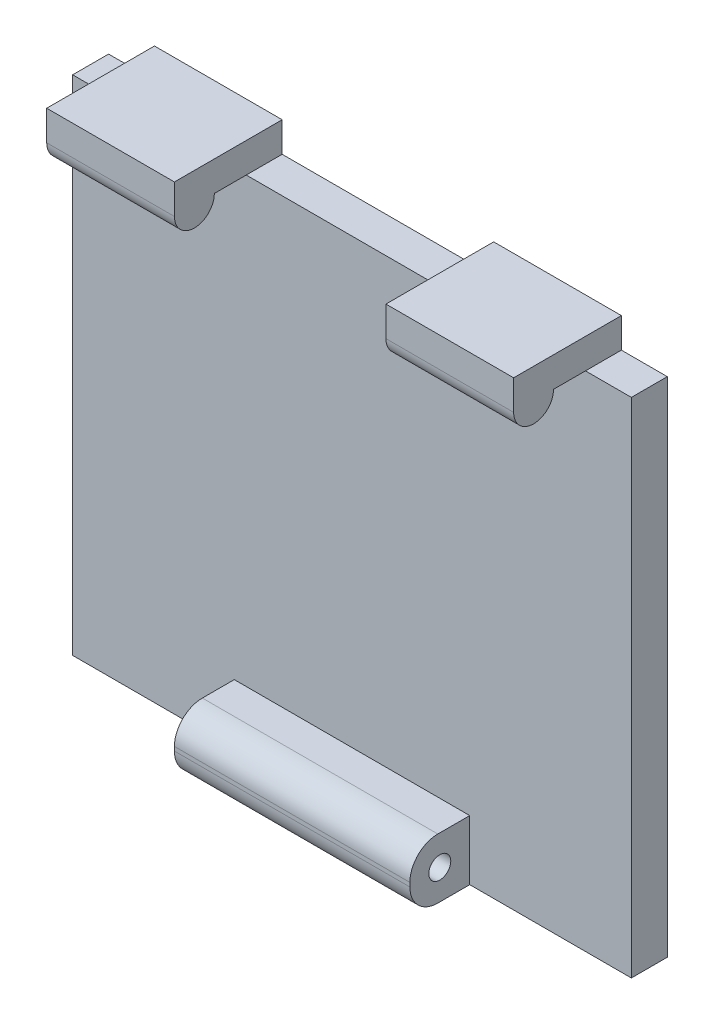
from build123d import *

# Parameters (mm, degrees)
SKETCH_1_W          = 28
SKETCH_1_H          = 25.2
EXTRUDE_1_DEPTH     = 1.8
SKETCH_2_W          = 11.8
SKETCH_2_H          = 3
EXTRUDE_2_DEPTH     = 3
FILLET_1_R          = 1.4
SKETCH_3_R          = 0.55
CUT_EXTRUDE_1_DEPTH = 20.9
SKETCH_4_W          = 6.4
SKETCH_4_H          = 1.8
EXTRUDE_3_DEPTH     = 1.5
SKETCH_5_W          = 6.4
SKETCH_5_H          = 1.5
EXTRUDE_4_DEPTH     = 3.6
SKETCH_7_R          = 1
EXTRUDE_5_DEPTH     = 6.4
SKETCH_8_R          = 1
EXTRUDE_6_DEPTH     = 6.4


with BuildPart() as part:
    # 草图1 → 凸台-拉伸1 (new body)
    with BuildSketch(Plane.XY):
        with Locations((14, -12.6)):
            Rectangle(SKETCH_1_W, SKETCH_1_H)
    extrude(amount=EXTRUDE_1_DEPTH)

    # 草图2 → 凸台-拉伸2 (add)
    with BuildSketch(Plane.XY.offset(1.8)):
        with Locations((14, -23.7)):
            Rectangle(SKETCH_2_W, SKETCH_2_H)
    extrude(amount=EXTRUDE_2_DEPTH)

    # 圆角1
    fillet_1_edges = [part.edges().sort_by_distance(p)[0] for p in [
        (14, -25.2, 4.8),
        (14, -22.2, 4.8),
    ]]
    fillet(fillet_1_edges, radius=FILLET_1_R)

    # 草图3 → 切除-拉伸1 (cut, through all)
    with BuildSketch(Plane(origin=(19.9, 0, 0), x_dir=(0, 0, -1), z_dir=(1, 0, 0))):
        with Locations((-3.3, -23.7)):
            Circle(SKETCH_3_R)
    extrude(amount=-CUT_EXTRUDE_1_DEPTH, mode=Mode.SUBTRACT)

    # 草图4 → 凸台-拉伸3 (add)
    with BuildSketch(Plane(origin=(0, 0, 0), x_dir=(1, 0, 0), z_dir=(0, 1, 0))):
        with Locations((5.5, -0.9)):
            Rectangle(SKETCH_4_W, SKETCH_4_H)
        with Locations((22.5, -0.9)):
            Rectangle(SKETCH_4_W, SKETCH_4_H)
    extrude(amount=EXTRUDE_3_DEPTH)

    # 草图5 → 凸台-拉伸4 (add)
    with BuildSketch(Plane.XY.offset(1.8)):
        with Locations((5.5, 0.75)):
            Rectangle(SKETCH_5_W, SKETCH_5_H)
        with Locations((22.5, 0.75)):
            Rectangle(SKETCH_5_W, SKETCH_5_H)
    extrude(amount=EXTRUDE_4_DEPTH)

    # 草图7 → 凸台-拉伸5 (add)
    with BuildSketch(Plane(origin=(25.7, 0, 0), x_dir=(0, 0, -1), z_dir=(1, 0, 0))):
        with Locations((-4.4, 0)):
            Circle(SKETCH_7_R)
    extrude(amount=-EXTRUDE_5_DEPTH)

    # 草图8 → 凸台-拉伸6 (add)
    with BuildSketch(Plane.ZY.offset(-2.3)):
        with Locations((4.4, 0)):
            Circle(SKETCH_8_R)
    extrude(amount=-EXTRUDE_6_DEPTH)


solid = part.part
